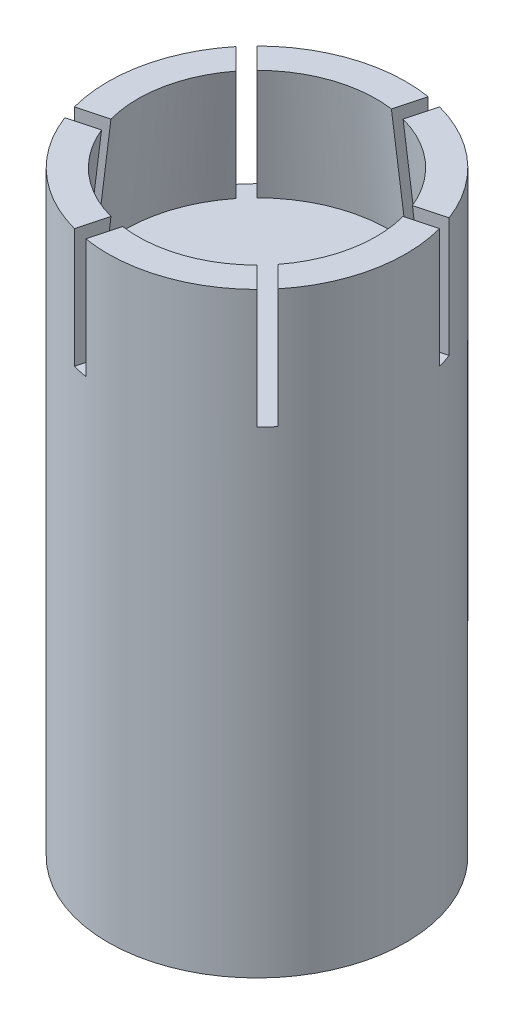
from build123d import *

# Parameters (mm, degrees)
SKETCH2_W             = 5
SKETCH2_H             = 20
SLOTS_START           = -4
SLOTS_DEPTH           = 4.5
SLOT_CIRPATTERN_COUNT = 6
SKETCH4_R             = 4
JOYSTICKHOLE_DEPTH    = 4
JOYSTICKHOLE_TAPER    = -6


with BuildPart() as part:
    # Sketch2 → Mount (revolve)
    with BuildSketch(Plane.XY):
        with Locations((2.5, -10)):
            Rectangle(SKETCH2_W, SKETCH2_H)
    revolve(axis=Axis((0, 5.533812346, 0), (0, -1, 0)))

    # Sketch3 → Slots (cut)
    with BuildSketch(Plane(origin=(0, 0, 0), x_dir=(1, 0, 0), z_dir=(0, 1, 0)).offset(SLOTS_START)):
        Polygon((-4.242640687, 4.242640687), (0, 0), (-0.353553391, -0.353553391), (-4.596194078, 3.889087297), align=None)
    slots = extrude(amount=SLOTS_DEPTH, mode=Mode.SUBTRACT)

    # Slot CirPattern: Slots ×6 about axis
    slot_cirpattern_axis = Axis((0, 0, 0), (0, 1, 0))
    for i in range(1, SLOT_CIRPATTERN_COUNT):
        add(slots.rotate(slot_cirpattern_axis, i * 360 / SLOT_CIRPATTERN_COUNT), mode=Mode.SUBTRACT)

    # Sketch4 → JoystickHole (cut)
    with BuildSketch(Plane(origin=(0, 0, 0), x_dir=(1, 0, 0), z_dir=(0, 1, 0))):
        Circle(SKETCH4_R)
    extrude(amount=-JOYSTICKHOLE_DEPTH, taper=JOYSTICKHOLE_TAPER, mode=Mode.SUBTRACT)


solid = part.part
